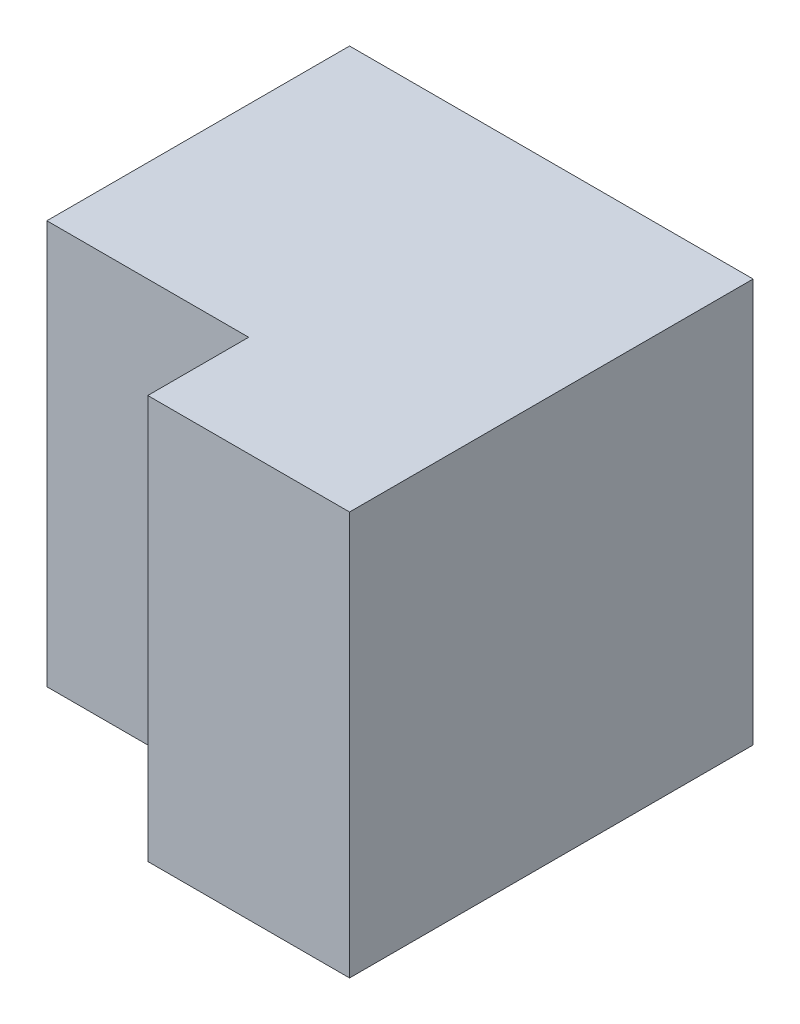
from build123d import *

# Parameters (mm, degrees)
SKETCH1_W           = 4
SKETCH1_H           = 4
BOSS_EXTRUDE1_DEPTH = 2
SKETCH2_W           = 3
SKETCH2_H           = 4
BOSS_EXTRUDE2_DEPTH = 2


with BuildPart() as part:
    # Sketch1 → Boss-Extrude1 (new body)
    with BuildSketch(Plane(origin=(0, 0, 0), x_dir=(0, 0, -1), z_dir=(1, 0, 0))):
        with Locations((2, 2)):
            Rectangle(SKETCH1_W, SKETCH1_H)
    extrude(amount=BOSS_EXTRUDE1_DEPTH)

    # Sketch2 → Boss-Extrude2 (add)
    with BuildSketch(Plane.ZY):
        with Locations((-2.5, 2)):
            Rectangle(SKETCH2_W, SKETCH2_H)
    extrude(amount=BOSS_EXTRUDE2_DEPTH)


solid = part.part
